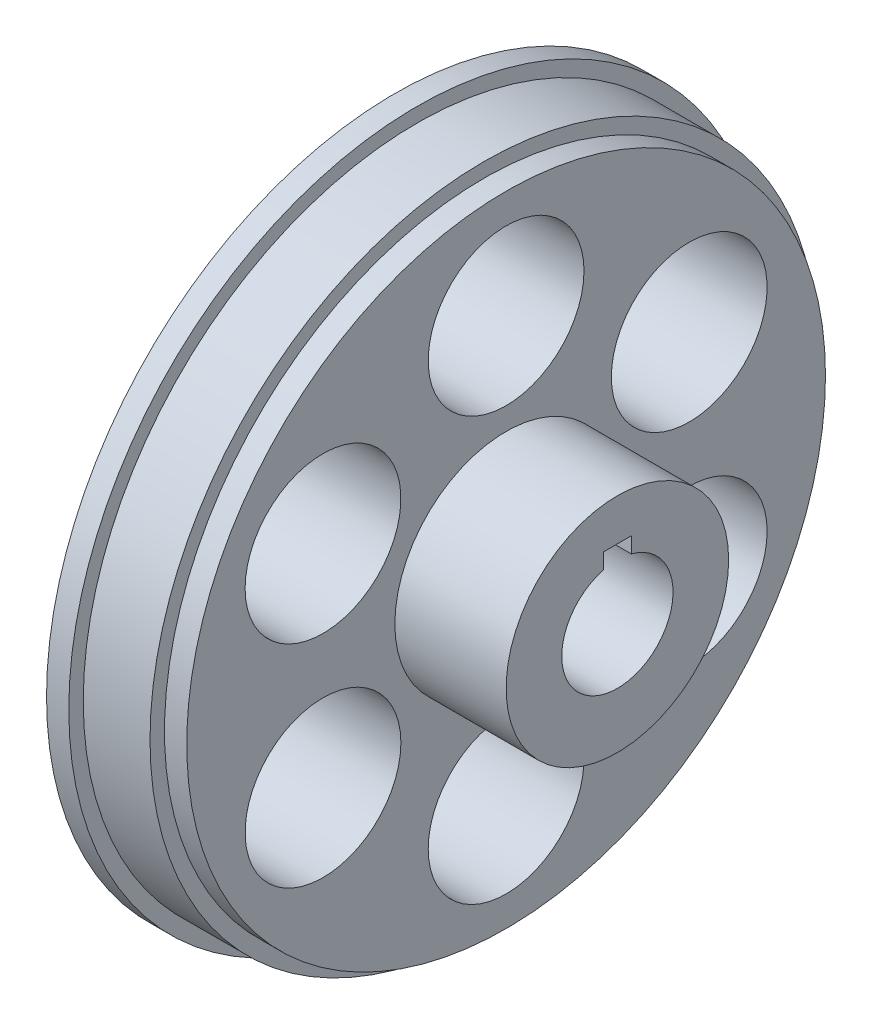
from build123d import *

# Parameters (mm, degrees)
SKETCH1_R           = 25.4
BOSS_EXTRUDE1_DEPTH = 25.4
SKETCH2_R           = 38.1
SKETCH2_R_2         = 10.9140625
BOSS_EXTRUDE2_DEPTH = 12.7
SKETCH3_R           = 25.4
SKETCH3_R_2         = 12.7
CUT_EXTRUDE1_DEPTH  = 12.7
SKETCH4_R           = 8.89
CUT_EXTRUDE2_DEPTH  = 13.7
CIRPATTERN1_COUNT   = 6
SKETCH5_R           = 39.751
SKETCH5_R_2         = 38.1
BOSS_EXTRUDE3_DEPTH = 2.54
SKETCH6_R           = 38.1
SKETCH6_R_2         = 36.449
CUT_EXTRUDE3_DEPTH  = 2.54


with BuildPart() as part:
    # Sketch1 → Boss-Extrude1 (new body)
    with BuildSketch(Plane(origin=(0, 0, 0), x_dir=(0, 0, -1), z_dir=(1, 0, 0))):
        Circle(SKETCH1_R)
        with BuildLine():
            Line((-1.5875, 6.148361062), (-1.5875, 7.9375))
            Line((-1.5875, 7.9375), (1.5875, 7.9375))
            Line((1.5875, 7.9375), (1.5875, 6.148361062))
            ThreePointArc((1.5875, 6.148361062), (5.020115786, 3.888564967), (6.35, 0))
            ThreePointArc((6.35, 0), (-3.888564967, -5.020115786), (-1.5875, 6.148361062))
        make_face(mode=Mode.SUBTRACT)
    extrude(amount=BOSS_EXTRUDE1_DEPTH)

    # Sketch2 → Boss-Extrude2 (add)
    with BuildSketch(Plane.ZY):
        Circle(SKETCH2_R)
        Circle(SKETCH2_R_2, mode=Mode.SUBTRACT)
    extrude(amount=-BOSS_EXTRUDE2_DEPTH)

    # Sketch3 → Cut-Extrude1 (cut)
    with BuildSketch(Plane(origin=(25.4, 0, 0), x_dir=(0, 0, -1), z_dir=(1, 0, 0))):
        Circle(SKETCH3_R)
        Circle(SKETCH3_R_2, mode=Mode.SUBTRACT)
    extrude(amount=-CUT_EXTRUDE1_DEPTH, mode=Mode.SUBTRACT)

    # Sketch4 → Cut-Extrude2 (cut, through all)
    with BuildSketch(Plane(origin=(12.7, 0, 0), x_dir=(0, 0, -1), z_dir=(1, 0, 0))):
        with Locations((0, 24.13)):
            Circle(SKETCH4_R)
    cut_extrude2 = extrude(amount=-CUT_EXTRUDE2_DEPTH, mode=Mode.SUBTRACT)

    # CirPattern1: Cut-Extrude2 ×6 about axis
    cirpattern1_axis = Axis((0, 0, 0), (1, 0, 0))
    for i in range(1, CIRPATTERN1_COUNT):
        add(cut_extrude2.rotate(cirpattern1_axis, i * 360 / CIRPATTERN1_COUNT), mode=Mode.SUBTRACT)

    # Sketch5 → Boss-Extrude3 (add)
    with BuildSketch(Plane.ZY):
        Circle(SKETCH5_R)
        Circle(SKETCH5_R_2, mode=Mode.SUBTRACT)
    extrude(amount=-BOSS_EXTRUDE3_DEPTH)

    # Sketch6 → Cut-Extrude3 (cut)
    with BuildSketch(Plane(origin=(12.7, 0, 0), x_dir=(0, 0, -1), z_dir=(1, 0, 0))):
        Circle(SKETCH6_R)
        Circle(SKETCH6_R_2, mode=Mode.SUBTRACT)
    extrude(amount=-CUT_EXTRUDE3_DEPTH, mode=Mode.SUBTRACT)


solid = part.part
